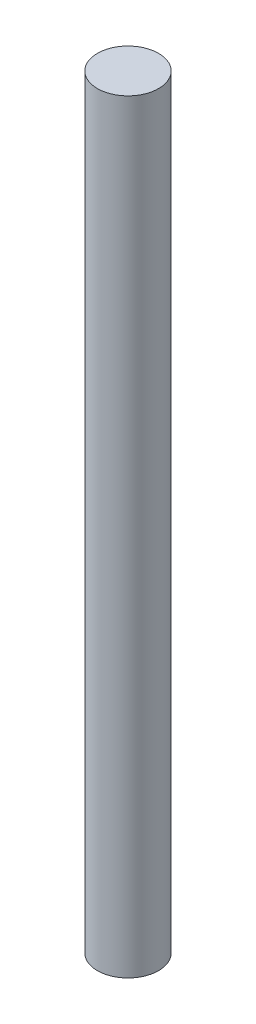
from build123d import *

# Parameters (mm, degrees)
SKETCH_1_R      = 4
EXTRUDE_1_DEPTH = 100


with BuildPart() as part:
    # 草图1 → 凸台-拉伸1 (new body)
    with BuildSketch(Plane(origin=(0, 0, 0), x_dir=(1, 0, 0), z_dir=(0, 1, 0))):
        Circle(SKETCH_1_R)
    extrude(amount=EXTRUDE_1_DEPTH)


solid = part.part
